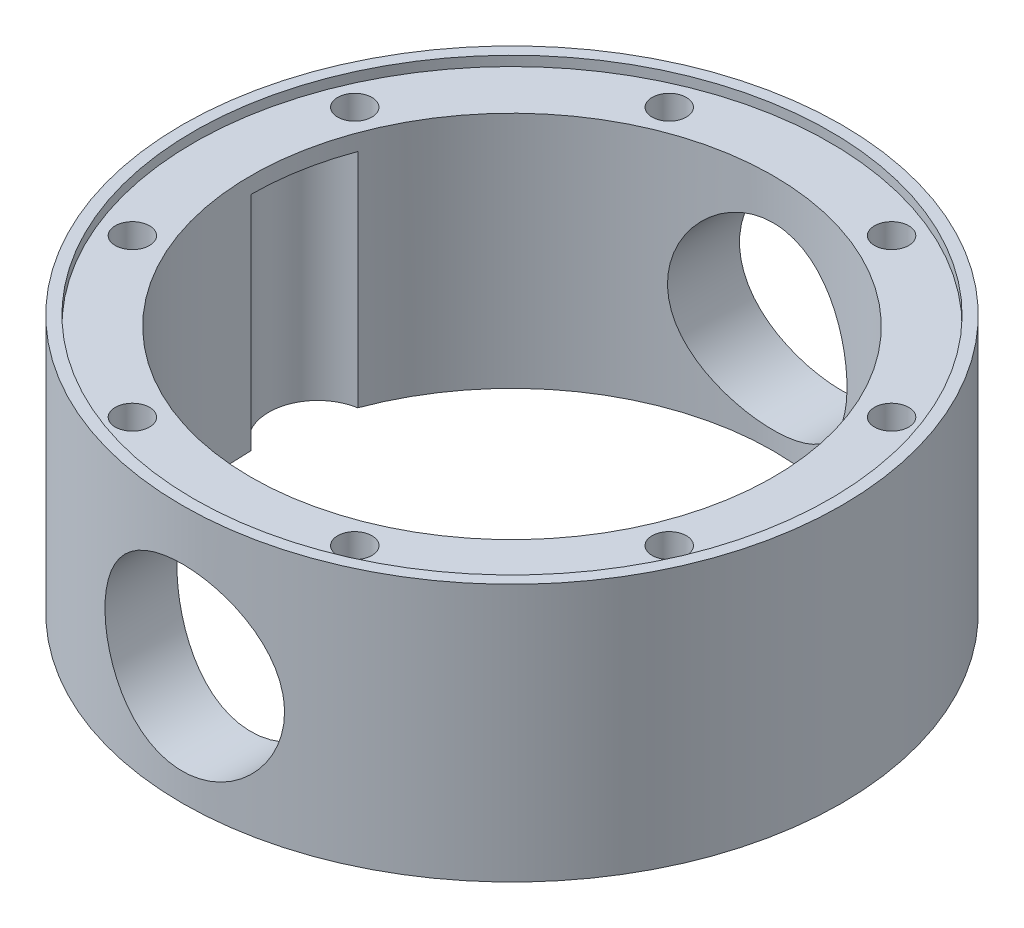
from build123d import *

# Parameters (mm, degrees)
SKETCH1_R               = 101
SKETCH1_R_2             = 80
BOSS_EXTRUDE1_DEPTH     = 38
SKETCH3_R               = 27.5
CUT_EXTRUDE1_DEPTH      = 102
CUT_EXTRUDE1_DEPTH_BACK = 102
SKETCH4_R               = 5.25
CUT_EXTRUDE2_DEPTH      = 76
CIRPATTERN1_COUNT       = 8
CUT_EXTRUDE3_DEPTH      = 68
SKETCH6_R               = 101
SKETCH6_R_2             = 97.5
BOSS_EXTRUDE2_DEPTH     = 3
SKETCH7_R               = 97.5
CUT_EXTRUDE4_DEPTH      = 3


with BuildPart() as part:
    # Sketch1 → Boss-Extrude1 (new body, symmetric)
    with BuildSketch(Plane(origin=(0, 0, 0), x_dir=(1, 0, 0), z_dir=(0, 1, 0))):
        Circle(SKETCH1_R)
        Circle(SKETCH1_R_2, mode=Mode.SUBTRACT)
    extrude(amount=BOSS_EXTRUDE1_DEPTH, both=True)

    # Sketch3 → Cut-Extrude1 (cut, two sides)
    with BuildSketch(Plane.XY) as cut_extrude1_sk:
        with Locations((0, -5)):
            Circle(SKETCH3_R)
    extrude(amount=CUT_EXTRUDE1_DEPTH, mode=Mode.SUBTRACT)
    extrude(cut_extrude1_sk.sketch, amount=-CUT_EXTRUDE1_DEPTH_BACK, mode=Mode.SUBTRACT)

    # Sketch4 → Cut-Extrude2 (cut)
    with BuildSketch(Plane(origin=(0, 38, 0), x_dir=(1, 0, 0), z_dir=(0, 1, 0))):
        with Locations((-34.05882548, 82.225278394)):
            Circle(SKETCH4_R)
    cut_extrude2 = extrude(amount=-CUT_EXTRUDE2_DEPTH, mode=Mode.SUBTRACT)

    # CirPattern1: Cut-Extrude2 ×8 about axis
    cirpattern1_axis = Axis((0, 0, 0), (0, 1, 0))
    for i in range(1, CIRPATTERN1_COUNT):
        add(cut_extrude2.rotate(cirpattern1_axis, i * 360 / CIRPATTERN1_COUNT), mode=Mode.SUBTRACT)

    # Sketch5 → Cut-Extrude3 (cut)
    with BuildSketch(Plane.XZ.offset(38)):
        with BuildLine():
            Line((-72.5, 2), (72.5, 2))
            ThreePointArc((72.5, 2), (87.5, -13), (72.5, -28))
            Line((72.5, -28), (-72.5, -28))
            ThreePointArc((-72.5, -28), (-87.5, -13), (-72.5, 2))
        make_face()
    extrude(amount=-CUT_EXTRUDE3_DEPTH, mode=Mode.SUBTRACT)

    # Sketch6 → Boss-Extrude2 (add)
    with BuildSketch(Plane.XZ.offset(38)):
        Circle(SKETCH6_R)
        Circle(SKETCH6_R_2, mode=Mode.SUBTRACT)
    extrude(amount=BOSS_EXTRUDE2_DEPTH)

    # Sketch7 → Cut-Extrude4 (cut)
    with BuildSketch(Plane(origin=(0, 38, 0), x_dir=(1, 0, 0), z_dir=(0, 1, 0))):
        Circle(SKETCH7_R)
    extrude(amount=-CUT_EXTRUDE4_DEPTH, mode=Mode.SUBTRACT)


solid = part.part
